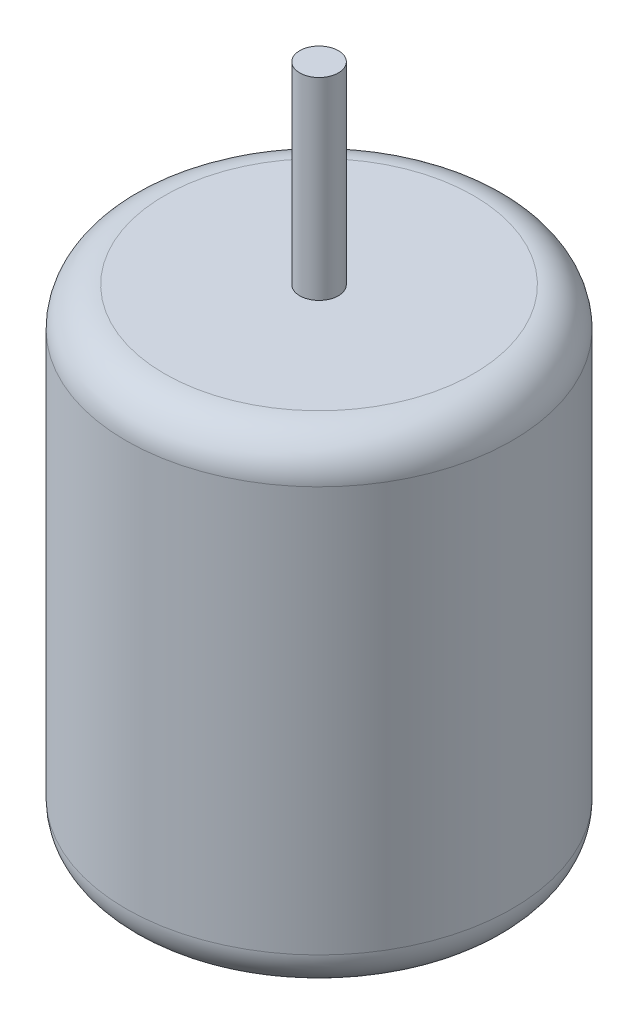
from build123d import *

# Parameters (mm, degrees)
SKETCH1_R           = 10
BOSS_EXTRUDE1_DEPTH = 25
SKETCH2_R           = 1
BOSS_EXTRUDE2_DEPTH = 10
FILLET1_R           = 2


with BuildPart() as part:
    # Sketch1 → Boss-Extrude1 (new body)
    with BuildSketch(Plane(origin=(0, 0, 0), x_dir=(1, 0, 0), z_dir=(0, 1, 0))):
        Circle(SKETCH1_R)
    extrude(amount=BOSS_EXTRUDE1_DEPTH)

    # Sketch2 → Boss-Extrude2 (add)
    with BuildSketch(Plane(origin=(0, 25, 0), x_dir=(1, 0, 0), z_dir=(0, 1, 0))):
        Circle(SKETCH2_R)
    extrude(amount=BOSS_EXTRUDE2_DEPTH)

    # Fillet1
    fillet1_edges = [part.edges().sort_by_distance(p)[0] for p in [
        (-10, 0, 0),
        (-10, 25, 0),
    ]]
    fillet(fillet1_edges, radius=FILLET1_R)


solid = part.part
